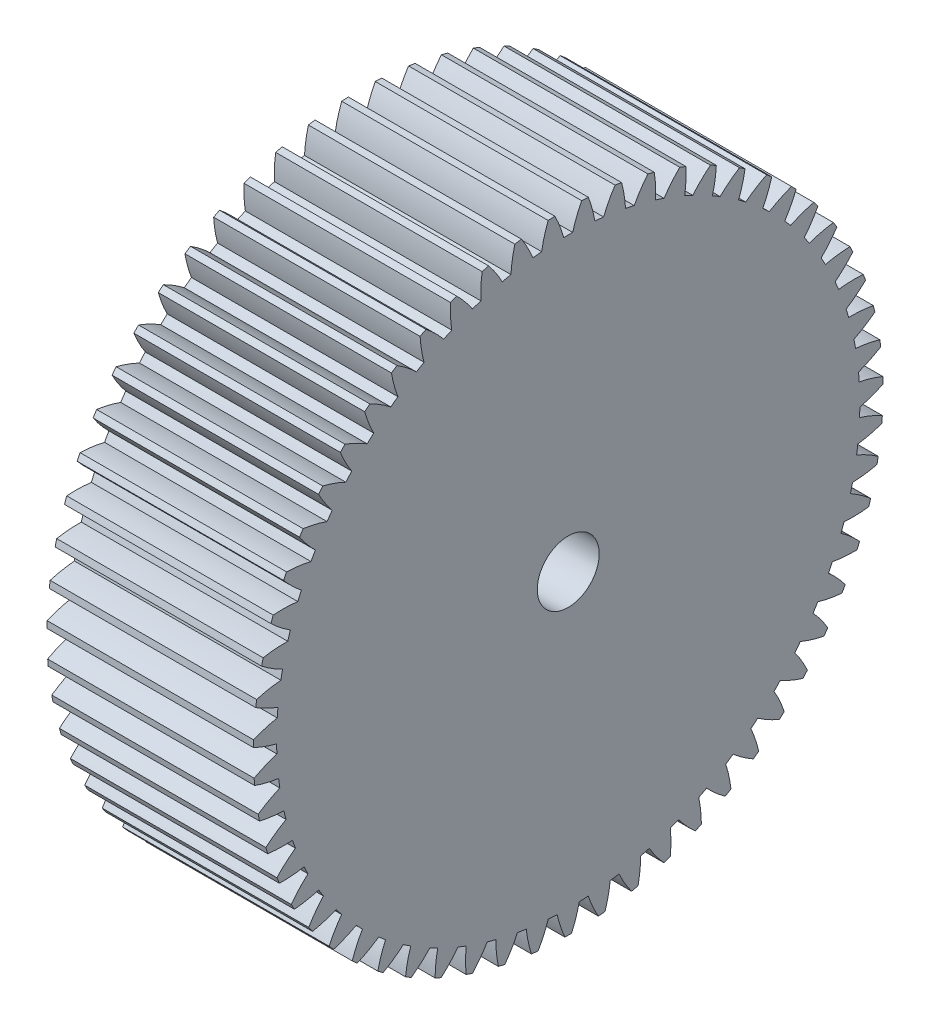
from build123d import *

# Parameters (mm, degrees)
BASPROSKE_W     = 10
BASPROSKE_H     = 15.25
TOOTHCUT_DEPTH  = 24.772357897
TEETHCUTS_COUNT = 59
TEETHCUTS_ANGLE = 353.898305085
BORSKE_R        = 1.5
BORE_DEPTH      = 50.0000508


with BuildPart() as part:
    # BasProSke → Base-Revolve (revolve)
    with BuildSketch(Plane(origin=(0, 0, 0), x_dir=(1, 0, 0), z_dir=(0, 1, 0)), mode=Mode.PRIVATE) as base_revolve_sk:
        with Locations((5, 7.625)):
            Rectangle(BASPROSKE_W, BASPROSKE_H)
    revolve(base_revolve_sk.sketch.rotate(Axis((-10, 0, 0), (1, 0, 0)), 180), axis=Axis((-10, 0, 0), (1, 0, 0)))

    # TooCutSke → ToothCut (cut, through all)
    with BuildSketch(Plane(origin=(0, 0, 0), x_dir=(0, 0, -1), z_dir=(1, 0, 0))):
        with BuildLine():
            ThreePointArc((0.215258607, 14.122359567), (0, 14.124), (-0.215258607, 14.122359567))
            ThreePointArc((-0.215258607, 14.122359567), (-0.409773942, 14.703323593), (-0.663487131, 15.260983913))
            ThreePointArc((-0.663487131, 15.260983913), (0, 15.2754), (0.663487131, 15.260983913))
            ThreePointArc((0.663487131, 15.260983913), (0.409773942, 14.703323593), (0.215258607, 14.122359567))
        make_face()
    toothcut = extrude(amount=TOOTHCUT_DEPTH, mode=Mode.SUBTRACT)

    # TeethCuts: ToothCut ×59 about axis
    teethcuts_axis = Axis((-10, 0, 0), (1, 0, 0))
    for i in range(1, TEETHCUTS_COUNT):
        add(toothcut.rotate(teethcuts_axis, i * TEETHCUTS_ANGLE / (TEETHCUTS_COUNT - 1)), mode=Mode.SUBTRACT)

    # BorSke → Bore (cut, symmetric)
    with BuildSketch(Plane(origin=(0, 0, 0), x_dir=(0, 0, -1), z_dir=(1, 0, 0))):
        with Locations(Location((0, 0, 0), (0, 0, 180))):
            Circle(BORSKE_R)
    extrude(amount=BORE_DEPTH, both=True, mode=Mode.SUBTRACT)


solid = part.part
